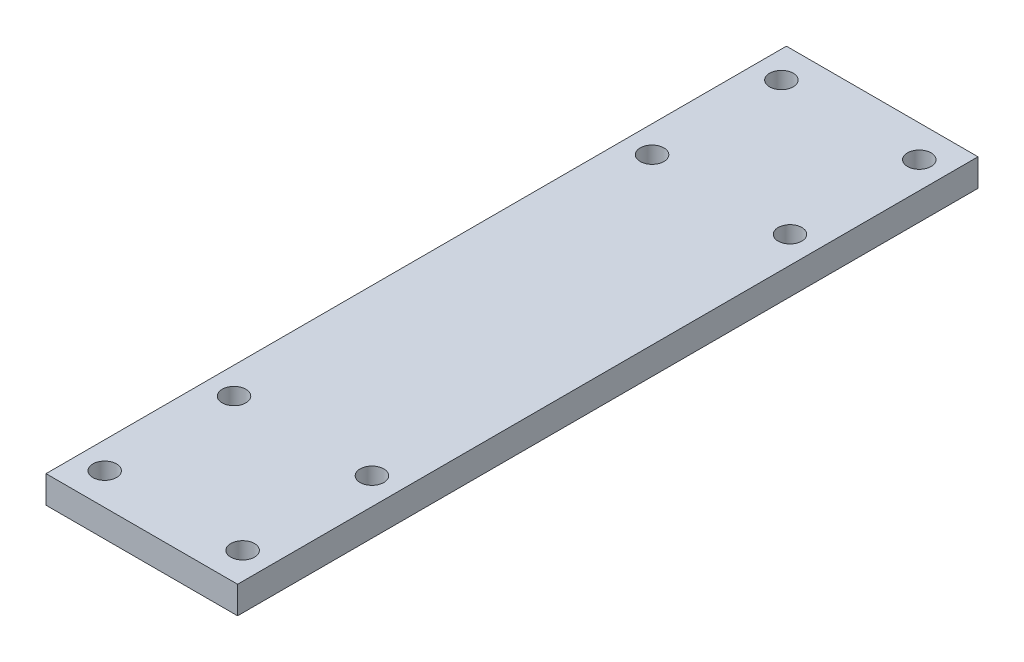
from build123d import *

# Parameters (mm, degrees)
SKETCH1_W            = 44.45
SKETCH1_H            = 171.789999828
BOSS_EXTRUDE1_DEPTH  = 6.35
M5_CLEARANCE_HOLE1_D = 5.5


with BuildPart() as part:
    # Sketch1 → Boss-Extrude1 (new body)
    with BuildSketch(Plane(origin=(0, 0, 0), x_dir=(1, 0, 0), z_dir=(0, 1, 0))):
        Rectangle(SKETCH1_W, SKETCH1_H)
    extrude(amount=BOSS_EXTRUDE1_DEPTH)

    # M5 Clearance Hole1 (through all)
    with Locations(Plane(origin=(0, 6.35, 0), x_dir=(1, 0, 0), z_dir=(0, 1, 0))):
        with Locations((-16, -48.5), (16, 78.5), (16, 48.5), (-16, 78.5), (-16, 48.5), (16, -48.5), (16, -78.5), (-16, -78.5)):
            Hole(M5_CLEARANCE_HOLE1_D / 2)


solid = part.part
